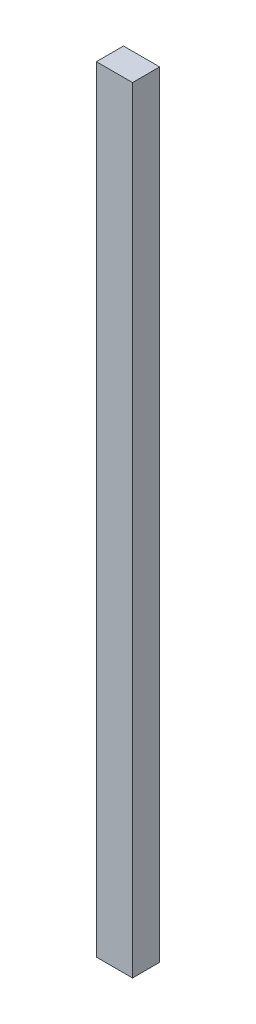
from build123d import *

# Parameters (mm, degrees)
SKETCH1_W           = 25.4
SKETCH1_H           = 19.05
BOSS_EXTRUDE1_DEPTH = 544.576


with BuildPart() as part:
    # Sketch1 → Boss-Extrude1 (new body)
    with BuildSketch(Plane(origin=(0, 0, 0), x_dir=(1, 0, 0), z_dir=(0, 1, 0))):
        with Locations((12.7, 9.525)):
            Rectangle(SKETCH1_W, SKETCH1_H)
    extrude(amount=BOSS_EXTRUDE1_DEPTH)


solid = part.part
